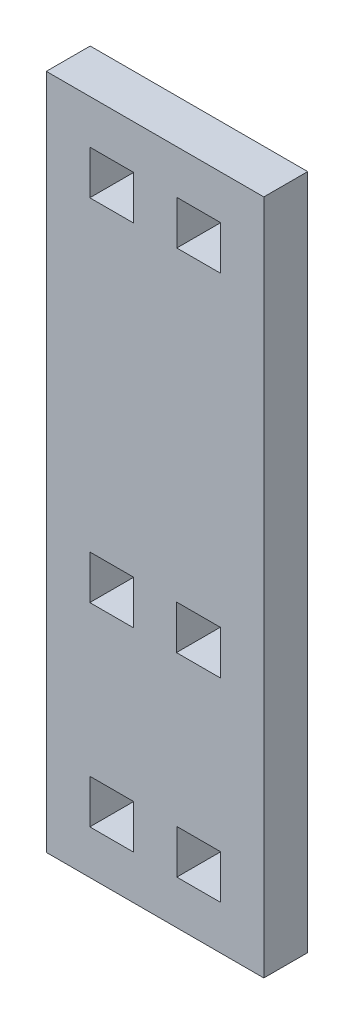
from build123d import *

# Parameters (mm, degrees)
SKETCH1_W           = 25.53
SKETCH1_H           = 79.4
BOSS_EXTRUDE1_DEPTH = 5.15
SKETCH2_W           = 5.106
SKETCH2_H           = 5.15
SKETCH2_W_2         = 5.15
CUT_EXTRUDE1_DEPTH  = 6.15


with BuildPart() as part:
    # Sketch1 → Boss-Extrude1 (new body)
    with BuildSketch(Plane.XY):
        with Locations((12.765, 39.7)):
            Rectangle(SKETCH1_W, SKETCH1_H)
    extrude(amount=BOSS_EXTRUDE1_DEPTH)

    # Sketch2 → Cut-Extrude1 (cut, through all)
    with BuildSketch(Plane.XY.offset(5.15)):
        with Locations((7.659, 71.675)):
            Rectangle(SKETCH2_W, SKETCH2_H)
        with Locations((17.871, 71.675)):
            Rectangle(SKETCH2_W, SKETCH2_H)
        with Locations((7.681, 30.525)):
            Rectangle(SKETCH2_W_2, SKETCH2_H)
        with Locations((17.849, 30.525)):
            Rectangle(SKETCH2_W_2, SKETCH2_H)
        with Locations((17.871, 7.725)):
            Rectangle(SKETCH2_W, SKETCH2_H)
        with Locations((7.659, 7.725)):
            Rectangle(SKETCH2_W, SKETCH2_H)
    extrude(amount=-CUT_EXTRUDE1_DEPTH, mode=Mode.SUBTRACT)


solid = part.part
